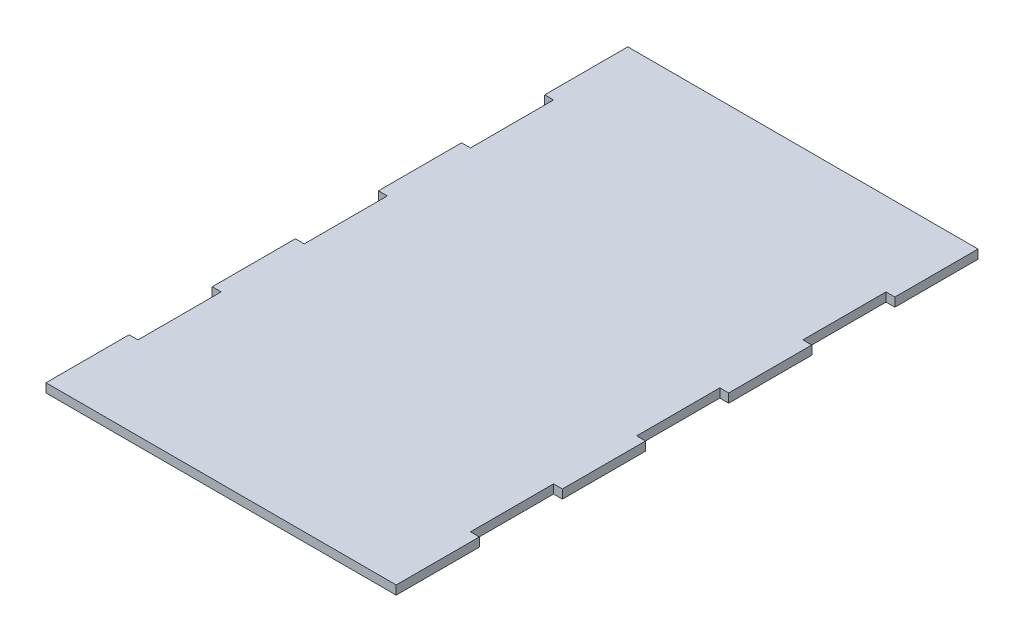
from build123d import *

# Parameters (mm, degrees)
BOSS_EXTRUDE1_DEPTH = 10.16


with BuildPart() as part:
    # Sketch1 → Boss-Extrude1 (new body)
    with BuildSketch(Plane(origin=(0, 0, 0), x_dir=(1, 0, 0), z_dir=(0, 1, 0))):
        Polygon((0, 95.25), (0, 0), (401.32, 0), (401.32, 95.25), (391.16, 95.25), (391.16, 190.5), (401.32, 190.5), (401.32, 285.75), (391.16, 285.75), (391.16, 381), (401.32, 381), (401.32, 476.25), (391.16, 476.25), (391.16, 571.5), (401.32, 571.5), (401.32, 666.75), (0, 666.75), (0, 571.5), (10.16, 571.5), (10.16, 476.25), (0, 476.25), (0, 381), (10.16, 381), (10.16, 285.75), (0, 285.75), (0, 190.5), (10.16, 190.5), (10.16, 95.25), align=None)
    extrude(amount=BOSS_EXTRUDE1_DEPTH)


solid = part.part
